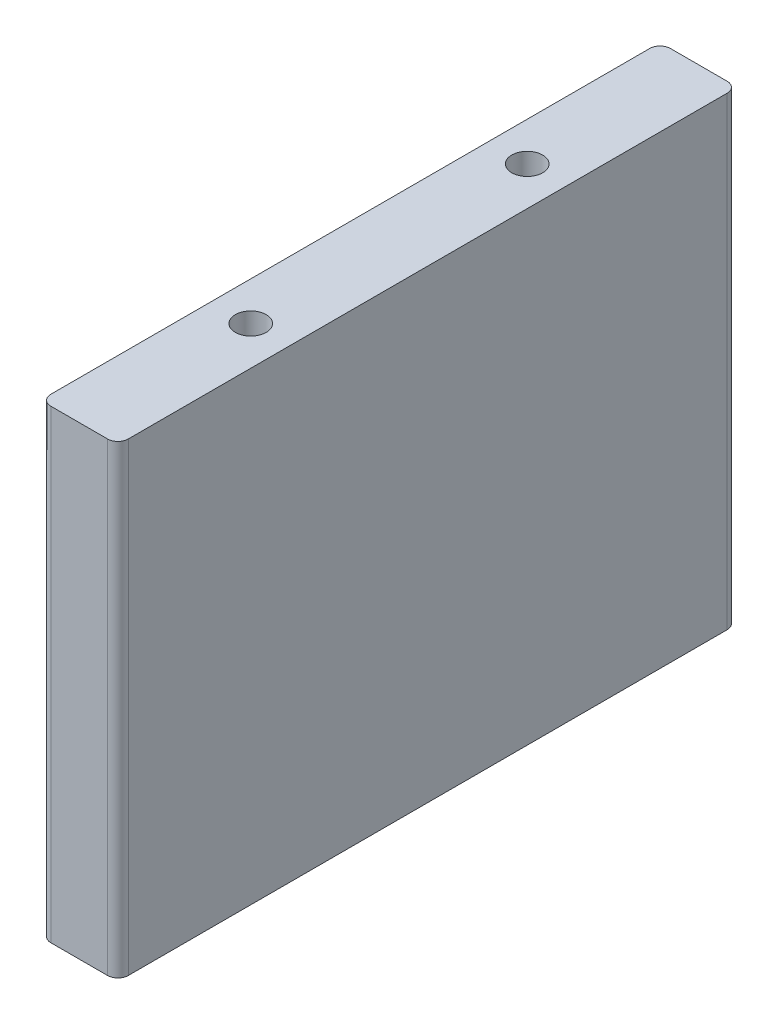
from build123d import *

# Parameters (mm, degrees)
SKETCH1_W                       = 9.525
SKETCH1_H                       = 76.2
BOSS_EXTRUDE1_DEPTH             = 28.575
F_10_24_TAPPED_HOLE1_AT_2_COUNT = 2
F_10_24_TAPPED_HOLE1_AT_2_PITCH = 34
FILLET1_R                       = 1.27


with BuildPart() as part:
    # Sketch1 → Boss-Extrude1 (new body, symmetric)
    with BuildSketch(Plane(origin=(0, 0, 0), x_dir=(1, 0, 0), z_dir=(0, 1, 0))):
        Rectangle(SKETCH1_W, SKETCH1_H)
    extrude(amount=BOSS_EXTRUDE1_DEPTH, both=True)

    # Sketch3 → #10-24 Tapped Hole1 (revolve, cut)
    with BuildSketch(Plane(origin=(0, 28.575, -17), x_dir=(0, 0, 1), z_dir=(1, 0, 0))):
        Polygon((0, 0), (0, 20.190824014), (1.89865, 19.05), (1.89865, 0), align=None)
    f_10_24_tapped_hole1 = revolve(axis=Axis((0, 34.925, -17), (0, -1, 0)), mode=Mode.SUBTRACT)

    # #10-24 Tapped Hole1 at 2: #10-24 Tapped Hole1 ×2
    with Locations(*[(0, 0, i * F_10_24_TAPPED_HOLE1_AT_2_PITCH) for i in range(1, F_10_24_TAPPED_HOLE1_AT_2_COUNT)]):
        add(f_10_24_tapped_hole1, mode=Mode.SUBTRACT)

    # Mirror1: #10-24 Tapped Hole1 across plane
    add(f_10_24_tapped_hole1.mirror(Plane.ZX), mode=Mode.SUBTRACT)

    # Mirror1 copy 1 sketch → Mirror1 copy 1 (revolve, cut)
    with BuildSketch(Plane(origin=(0, -28.575, 17), x_dir=(0, 0, 1), z_dir=(1, 0, 0))):
        Polygon((0, 0), (0, -20.190824014), (1.89865, -19.05), (1.89865, 0), align=None)
    revolve(axis=Axis((0, -34.925, 17), (0, -1, 0)), mode=Mode.SUBTRACT)

    # Fillet1
    fillet1_edges = [part.edges().sort_by_distance(p)[0] for p in [
        (-4.7625, 0, -38.1),
        (4.7625, 0, -38.1),
        (4.7625, 0, 38.1),
        (-4.7625, 0, 38.1),
    ]]
    fillet(fillet1_edges, radius=FILLET1_R)


solid = part.part
